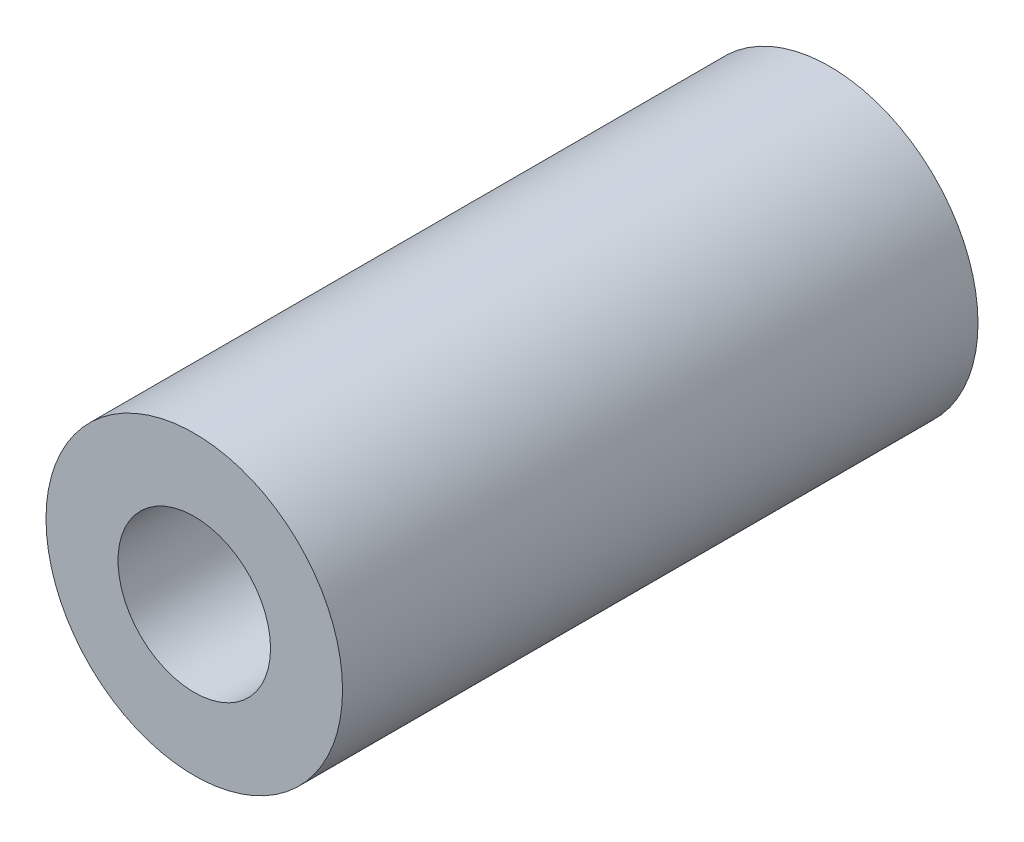
from build123d import *

# Parameters (mm, degrees)
SZKIC1_R                    = 3.5
SZKIC1_R_2                  = 1.8
DODANIE_WYCI_GNI_CIE1_DEPTH = 15


with BuildPart() as part:
    # Szkic1 → Dodanie-wyciągnięcie1 (new body)
    with BuildSketch(Plane.XY):
        Circle(SZKIC1_R)
        Circle(SZKIC1_R_2, mode=Mode.SUBTRACT)
    extrude(amount=DODANIE_WYCI_GNI_CIE1_DEPTH)


solid = part.part
